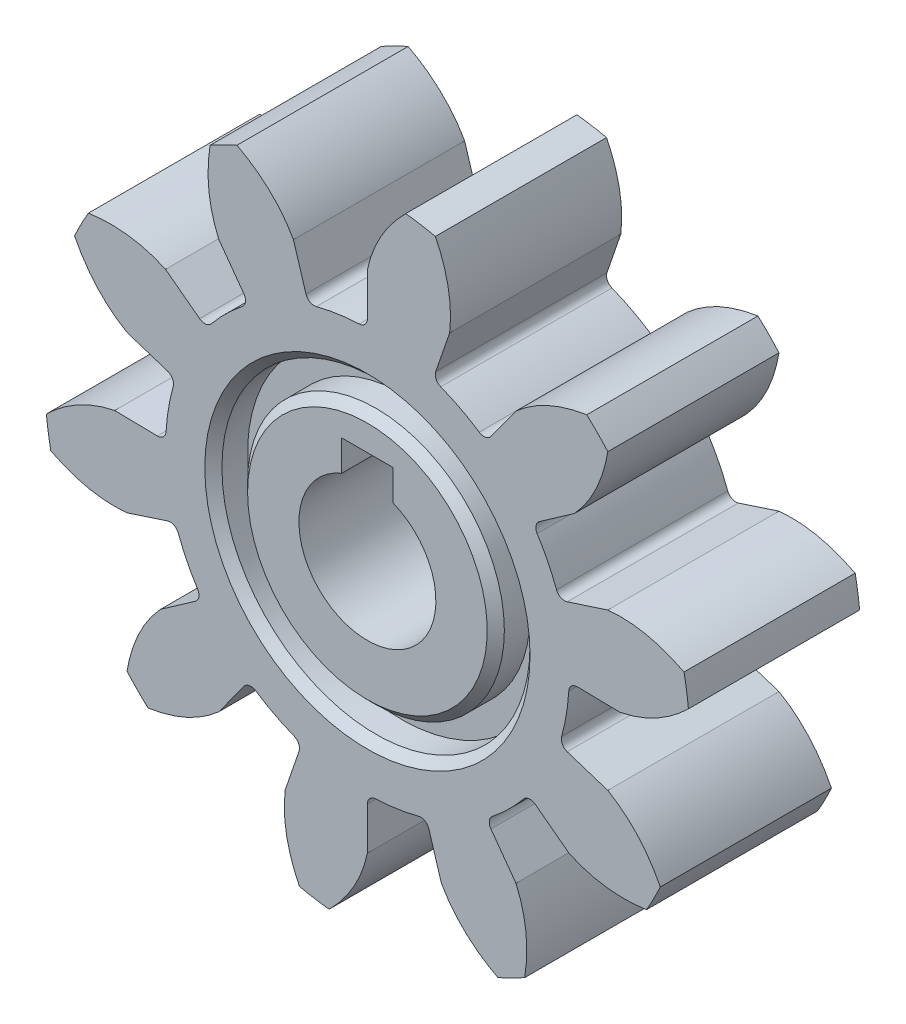
from build123d import *

# Parameters (mm, degrees)
BOSS_EXTRUDE1_DEPTH     = 10
CIRPATTERN1_COUNT       = 10
SKETCH1_R               = 11.7825
BOSS_EXTRUDE2_DEPTH     = 10
SKETCH4_R               = 9
SKETCH4_R_2             = 7.5
CUT_EXTRUDE1_DEPTH      = 2
SKETCH4_3_R             = 4
CUT_EXTRUDE2_DEPTH      = 29.32125352
CUT_EXTRUDE3_START      = -2
SKETCH5_R               = 9
SKETCH5_R_2             = 7.5
CUT_EXTRUDE3_DEPTH      = 2
FILLET1_R               = 0.5
CHAMFER1_SIZE           = 0.5
CHAMFER2_SIZE           = 0.5
CUT_EXTRUDE4_DEPTH      = 29.32125352
CUT_EXTRUDE4_DEPTH_BACK = 29.32125352
SKETCH6_W               = 3
SKETCH6_H               = 3


with BuildPart() as part:
    # Sketch3 → Boss-Extrude1 (new body)
    with BuildSketch(Plane.XY):
        with BuildLine():
            Line((4.803075617, 13.959368513), (3.833494733, 11.141437267))
            ThreePointArc((3.833494733, 11.141437267), (1.943363276, 11.621129266), (0, 11.7825))
            Line((0, 11.7825), (0, 14.762571073))
            add(Edge.make_bspline(
                [(0, 14.762571073), (0.333518774, 16.315241106), (1.140884964, 17.626707575), (2.241097954, 18.718316804)],
                knots=[0, 0, 0, 0, 0.256830749, 0.256830749, 0.256830749, 0.256830749], degree=3))
            ThreePointArc((2.241097954, 18.718316804), (3.109381242, 18.593806826), (3.970932877, 18.429042191))
            add(Edge.make_bspline(
                [(4.803075617, 13.959368513), (4.992871831, 15.536072798), (4.656124965, 17.038865536), (3.970932877, 18.429042191)],
                knots=[0, 0, 0, 0, 0.256830749, 0.256830749, 0.256830749, 0.256830749], degree=3))
        make_face()
    extrude(amount=BOSS_EXTRUDE1_DEPTH)


with BuildPart() as cirpattern1_1:
    # CirPattern1: pattern copy
    add(part.part.rotate(Axis((0, 0, 0), (0, 0, 1)), 1 * 360 / CIRPATTERN1_COUNT))


with BuildPart() as cirpattern1_2:
    # CirPattern1: pattern copy
    add(part.part.rotate(Axis((0, 0, 0), (0, 0, 1)), 2 * 360 / CIRPATTERN1_COUNT))


with BuildPart() as cirpattern1_3:
    # CirPattern1: pattern copy
    add(part.part.rotate(Axis((0, 0, 0), (0, 0, 1)), 3 * 360 / CIRPATTERN1_COUNT))


with BuildPart() as cirpattern1_4:
    # CirPattern1: pattern copy
    add(part.part.rotate(Axis((0, 0, 0), (0, 0, 1)), 4 * 360 / CIRPATTERN1_COUNT))


with BuildPart() as cirpattern1_5:
    # CirPattern1: pattern copy
    add(part.part.rotate(Axis((0, 0, 0), (0, 0, 1)), 5 * 360 / CIRPATTERN1_COUNT))


with BuildPart() as cirpattern1_6:
    # CirPattern1: pattern copy
    add(part.part.rotate(Axis((0, 0, 0), (0, 0, 1)), 6 * 360 / CIRPATTERN1_COUNT))


with BuildPart() as cirpattern1_7:
    # CirPattern1: pattern copy
    add(part.part.rotate(Axis((0, 0, 0), (0, 0, 1)), 7 * 360 / CIRPATTERN1_COUNT))


with BuildPart() as cirpattern1_8:
    # CirPattern1: pattern copy
    add(part.part.rotate(Axis((0, 0, 0), (0, 0, 1)), 8 * 360 / CIRPATTERN1_COUNT))


with BuildPart() as cirpattern1_9:
    # CirPattern1: pattern copy
    add(part.part.rotate(Axis((0, 0, 0), (0, 0, 1)), 9 * 360 / CIRPATTERN1_COUNT))


with BuildPart() as part_1:
    add(part.part)

    add(cirpattern1_1.part)  # Boss-Extrude2 merges CirPattern1_1

    add(cirpattern1_2.part)  # Boss-Extrude2 merges CirPattern1_2

    add(cirpattern1_3.part)  # Boss-Extrude2 merges CirPattern1_3

    add(cirpattern1_4.part)  # Boss-Extrude2 merges CirPattern1_4

    add(cirpattern1_5.part)  # Boss-Extrude2 merges CirPattern1_5

    add(cirpattern1_6.part)  # Boss-Extrude2 merges CirPattern1_6

    add(cirpattern1_7.part)  # Boss-Extrude2 merges CirPattern1_7

    add(cirpattern1_8.part)  # Boss-Extrude2 merges CirPattern1_8

    add(cirpattern1_9.part)  # Boss-Extrude2 merges CirPattern1_9
    # Sketch1 → Boss-Extrude2 (add)
    with BuildSketch(Plane.XY):
        Circle(SKETCH1_R)
    extrude(amount=BOSS_EXTRUDE2_DEPTH)

    # Sketch4 → Cut-Extrude1 (cut)
    with BuildSketch(Plane.XY.offset(10)):
        Circle(SKETCH4_R)
        Circle(SKETCH4_R_2, mode=Mode.SUBTRACT)
    extrude(amount=-CUT_EXTRUDE1_DEPTH, mode=Mode.SUBTRACT)

    # Sketch4_3 → Cut-Extrude2 (cut, through all)
    with BuildSketch(Plane.XY.offset(10)):
        Circle(SKETCH4_3_R)
    extrude(amount=-CUT_EXTRUDE2_DEPTH, mode=Mode.SUBTRACT)

    # Sketch5 → Cut-Extrude3 (cut)
    with BuildSketch(Plane(origin=(0, 0, 0), x_dir=(-1, 0, 0), z_dir=(0, 0, -1)).offset(CUT_EXTRUDE3_START)):
        Circle(SKETCH5_R)
        Circle(SKETCH5_R_2, mode=Mode.SUBTRACT)
    extrude(amount=CUT_EXTRUDE3_DEPTH, mode=Mode.SUBTRACT)

    # Fillet1
    fillet1_edges = [part_1.edges().sort_by_distance(p)[0] for p in [
        (-3.447410128, 11.26688376, 5),
        (-11.205823403, 3.640992736, 5),
        (-6.925579735, 9.532242736, 5),
        (-9.650134902, -6.760340422, 5),
        (-11.780751534, 0.202976689, 5),
        (-9.411521493, 7.088763604, 5),
        (0, 11.7825, 5),
        (6.925579735, 9.532242736, 5),
        (-3.833494733, -11.141437267, 5),
        (-11.205823403, -3.640992736, 5),
        (-6.925579735, -9.532242736, 5),
        (0, -11.7825, 5),
        (3.447410128, -11.26688376, 5),
        (9.411521493, -7.088763604, 5),
        (3.833494733, 11.141437267, 5),
        (6.925579735, -9.532242736, 5),
        (11.205823403, -3.640992736, 5),
        (11.780751534, -0.202976689, 5),
        (11.205823403, 3.640992736, 5),
        (9.650134902, 6.760340422, 5),
    ]]
    fillet(fillet1_edges, radius=FILLET1_R)

    # Chamfer1
    chamfer1_edges = [part_1.edges().sort_by_distance(p)[0] for p in [
        (7.5, 0, 0),
        (-7.5, 0, 10),
    ]]
    chamfer(chamfer1_edges, length=CHAMFER1_SIZE)

    # Chamfer2
    chamfer2_edges = [part_1.edges().sort_by_distance(p)[0] for p in [
        (-9, 0, 10),
        (9, 0, 0),
    ]]
    chamfer(chamfer2_edges, length=CHAMFER2_SIZE)

    # Sketch6 → Cut-Extrude4 (cut, two sides: drawn at the far end of the back side and taken through both)
    with BuildSketch(Plane.XY.offset(-CUT_EXTRUDE4_DEPTH_BACK)):
        with Locations((0, 4)):
            Rectangle(SKETCH6_W, SKETCH6_H)
    extrude(amount=CUT_EXTRUDE4_DEPTH + CUT_EXTRUDE4_DEPTH_BACK, mode=Mode.SUBTRACT)


solid = part_1.part
